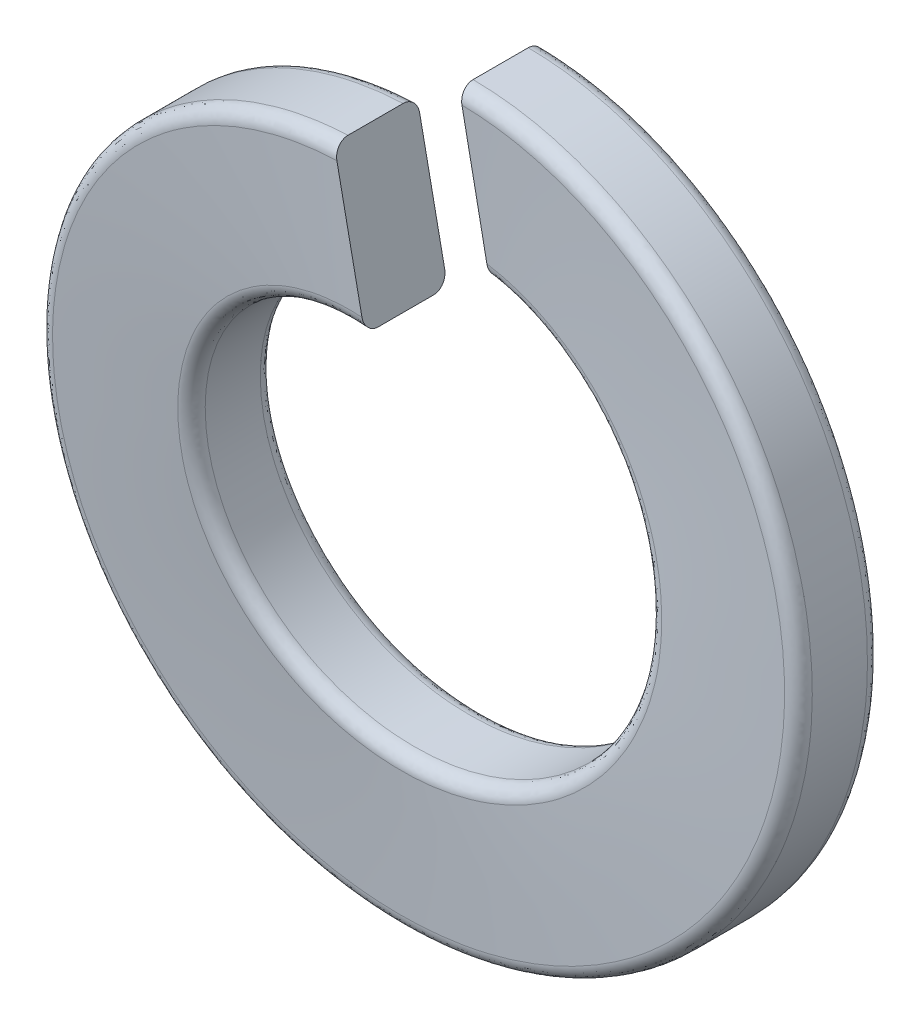
from build123d import *

# Parameters (mm, degrees)
SWEEP1_PITCH       = 0.800801
SWEEP1_HEIGHT      = 0.8
SWEEP1_RADIUS      = 2.55
SWEEP1_START_ANGLE = 85
CUT_EXTRUDE1_DEPTH = 1.7
FILLET1_R          = 0.1


with BuildPart() as part:
    # Sweep1: sweep along a helix
    with BuildLine() as sweep1_path:
        add(Helix(SWEEP1_PITCH, SWEEP1_HEIGHT, SWEEP1_RADIUS, center=(0, 0, 0.4), direction=(0, 0, -1), lefthand=True, mode=Mode.PRIVATE).rotate(Axis((0, 0, 0.4), (0, 0, -1)), SWEEP1_START_ANGLE))
    # Sketch4 → Sweep1 (sweep)
    with BuildSketch(Plane(origin=(0.312685, -0.083965, 0.005065), x_dir=(0.006985, -0.034268, -0.999388), z_dir=(0.97985, 0.199734, 0))):
        Polygon((-0.788176, 2.652285), (-0.188543, 2.673268), (-0.149628, 1.561232), (-0.749261, 1.540248), align=None)
    sweep(path=sweep1_path.line, is_frenet=True)

    # Sketch5 → Cut-Extrude1 (cut, through all)
    with BuildSketch(Plane.XY):
        with BuildLine():
            Line((0, 1.45), (-0.222247, 2.540296))
            ThreePointArc((-0.222247, 2.540296), (-0.166778, 2.54454), (-0.111229, 2.547573))
            Line((-0.111229, 2.547573), (0.113406, 1.445558))
            ThreePointArc((0.113406, 1.445558), (0.056747, 1.448889), (0, 1.45))
        make_face()
    extrude(amount=-CUT_EXTRUDE1_DEPTH, mode=Mode.SUBTRACT)

    # Fillet1
    fillet1_edges = [part.edges().sort_by_distance(p)[0] for p in [
        (0.166778, -2.544538, 0.30238),
        (0.166778, -2.544538, -0.29762),
        (-0.056747, -1.448888, 0.304589),
        (-0.056747, -1.448888, -0.295411),
    ]]
    fillet(fillet1_edges, radius=FILLET1_R)


solid = part.part
